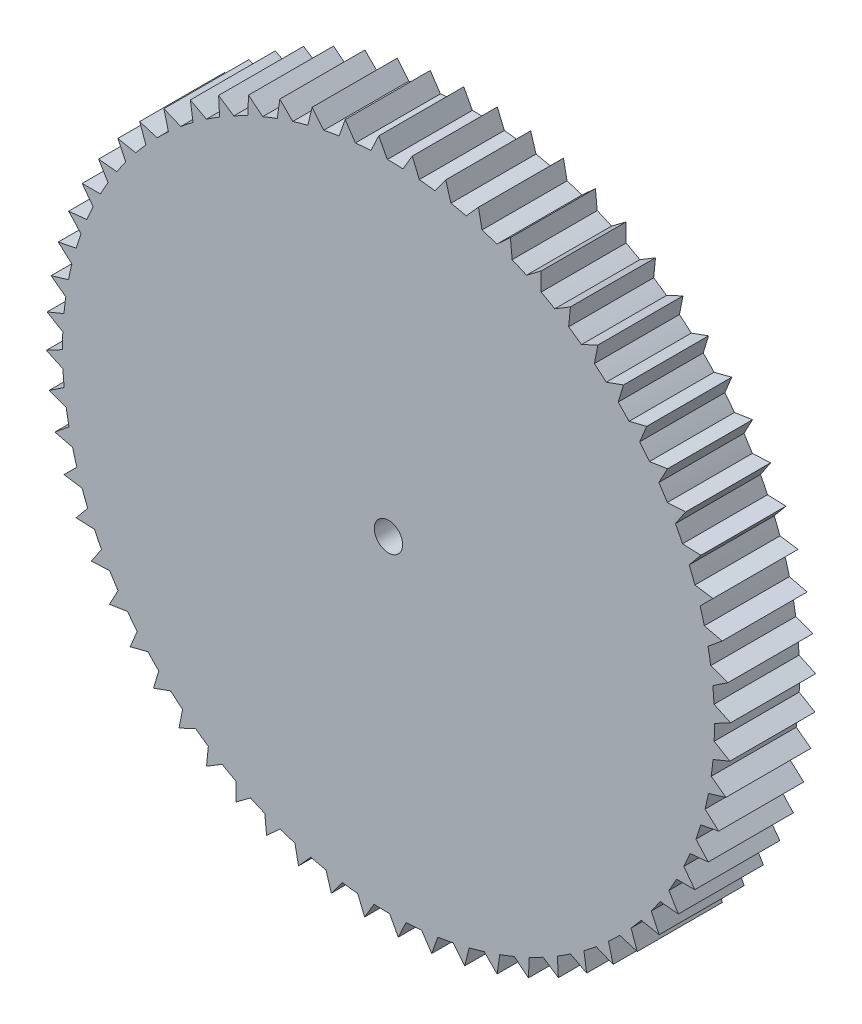
from build123d import *

# Parameters (mm, degrees)
SKETCH3_R           = 11.5
BOSS_EXTRUDE1_DEPTH = 3
SKETCH7_R           = 2
BOSS_EXTRUDE4_DEPTH = 3
BOSS_EXTRUDE5_DEPTH = 3
CIRPATTERN2_COUNT   = 20
SKETCH9_R           = 0.5
CUT_EXTRUDE1_DEPTH  = 6
BOSS_EXTRUDE6_DEPTH = 3
CIRPATTERN3_COUNT   = 64


with BuildPart() as part:
    # Sketch3 → Boss-Extrude1 (new body)
    with BuildSketch(Plane(origin=(0, 0, -25.970633743), x_dir=(-1, 0, 0), z_dir=(0, 0, -1))):
        with Locations((0, 64.2)):
            Circle(SKETCH3_R)
    extrude(amount=BOSS_EXTRUDE1_DEPTH)

    # Sketch7 → Boss-Extrude4 (add)
    with BuildSketch(Plane(origin=(0, 0, -28.970633743), x_dir=(-1, 0, 0), z_dir=(0, 0, -1))):
        with Locations((0, 64.2)):
            Circle(SKETCH7_R)
    extrude(amount=BOSS_EXTRUDE4_DEPTH)

    # Sketch8 → Boss-Extrude5 (add)
    with BuildSketch(Plane(origin=(0, 0, -31.970633743), x_dir=(-1, 0, 0), z_dir=(0, 0, -1))):
        Polygon((0.4, 62.4), (-0.4, 62.4), (0, 61.6), align=None)
    boss_extrude5 = extrude(amount=-BOSS_EXTRUDE5_DEPTH)

    # CirPattern2: Boss-Extrude5 ×20 about axis
    cirpattern2_axis = Axis((0, 64.168195033, 0), (0, 0, 1))
    for i in range(1, CIRPATTERN2_COUNT):
        add(boss_extrude5.rotate(cirpattern2_axis, i * 360 / CIRPATTERN2_COUNT))

    # Sketch9 → Cut-Extrude1 (cut)
    with BuildSketch(Plane(origin=(0, 0, -31.970633743), x_dir=(-1, 0, 0), z_dir=(0, 0, -1))):
        with Locations((0, 64.2)):
            Circle(SKETCH9_R)
    extrude(amount=-CUT_EXTRUDE1_DEPTH, mode=Mode.SUBTRACT)

    # Sketch10 → Boss-Extrude6 (add)
    with BuildSketch(Plane.XY.offset(-25.970633743)):
        Polygon((0.840227151, 76.244304594), (0.496992369, 75.665329133), (1.097338125, 75.623448193), align=None)
    boss_extrude6 = extrude(amount=-BOSS_EXTRUDE6_DEPTH)

    # CirPattern3: Boss-Extrude6 ×64 about axis
    cirpattern3_axis = Axis((0, 64.2, 0), (0, 0, 1))
    for i in range(1, CIRPATTERN3_COUNT):
        add(boss_extrude6.rotate(cirpattern3_axis, i * 360 / CIRPATTERN3_COUNT))


solid = part.part
